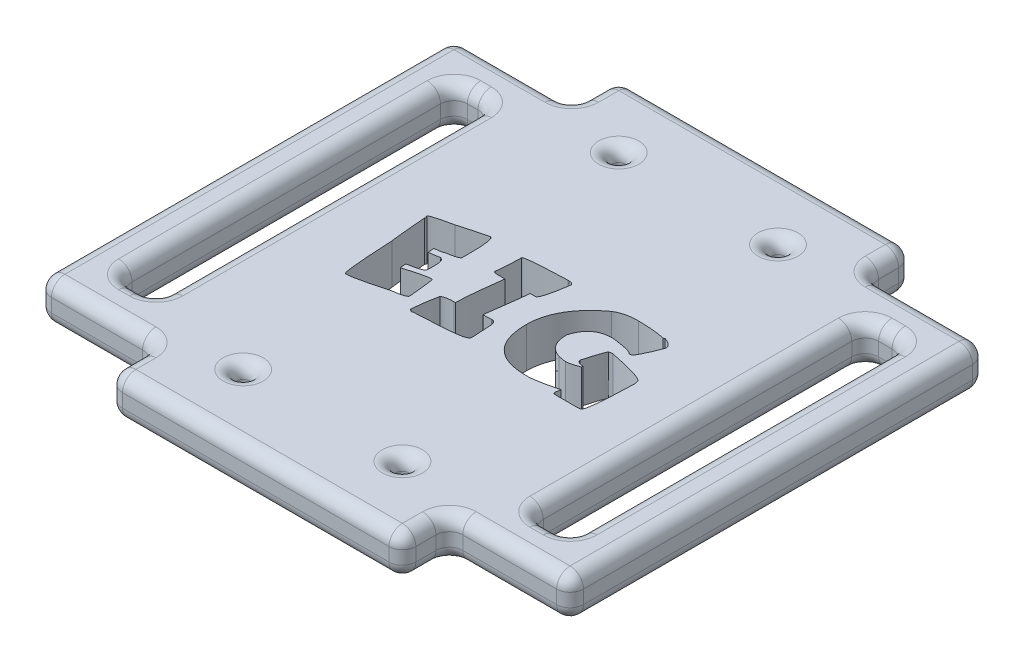
from build123d import *

# Parameters (mm, degrees)
SKETCH1_W           = 21.87178063
SKETCH1_H           = 38
BOSS_EXTRUDE2_DEPTH = 3
SKETCH8_W           = 8.788754456
SKETCH8_H           = 31
SKETCH8_W_2         = 2.788754456
SKETCH8_H_2         = 25
SKETCH8_W_3         = 9
SKETCH8_W_4         = 3
BOSS_EXTRUDE5_DEPTH = 3
SKETCH11_R          = 0.5
CUT_EXTRUDE5_DEPTH  = 3
FILLET1_R           = 1
CUT_EXTRUDE6_DEPTH  = 3


with BuildPart() as part:
    # Sketch1 → Boss-Extrude2 (new body)
    with BuildSketch(Plane(origin=(0, 0, 0), x_dir=(1, 0, 0), z_dir=(0, 1, 0))):
        with Locations((10.935890315, 19)):
            Rectangle(SKETCH1_W, SKETCH1_H)
    extrude(amount=BOSS_EXTRUDE2_DEPTH)

    # Sketch8 → Boss-Extrude5 (add)
    with BuildSketch(Plane(origin=(0, 0, 0), x_dir=(1, 0, 0), z_dir=(0, 1, 0))):
        with Locations((-4.394377228, 19)):
            Rectangle(SKETCH8_W, SKETCH8_H)
        with Locations((-4.394377228, 19)):
            Rectangle(SKETCH8_W_2, SKETCH8_H_2, mode=Mode.SUBTRACT)
        with Locations((26.37178063, 19)):
            Rectangle(SKETCH8_W_3, SKETCH8_H)
        with Locations((26.37178063, 19)):
            Rectangle(SKETCH8_W_4, SKETCH8_H_2, mode=Mode.SUBTRACT)
    extrude(amount=BOSS_EXTRUDE5_DEPTH)

    # Sketch11 → Cut-Extrude5 (cut)
    with BuildSketch(Plane(origin=(0, 3, 0), x_dir=(1, 0, 0), z_dir=(0, 1, 0))):
        with Locations((5, 33)):
            Circle(SKETCH11_R)
        with Locations((16.87178063, 33)):
            Circle(SKETCH11_R)
        with Locations((5, 5)):
            Circle(SKETCH11_R)
        with Locations((16.87178063, 5)):
            Circle(SKETCH11_R)
    extrude(amount=-CUT_EXTRUDE5_DEPTH, mode=Mode.SUBTRACT)

    # Fillet1
    fillet1_edges = [part.edges().sort_by_distance(p)[0] for p in [
        (21.87178063, 3, -1.75),
        (10.935890315, 3, 0),
        (0, 0, -36.25),
        (0, 3, -36.25),
        (-4.394377228, 3, -34.5),
        (-8.788754456, 3, -19),
        (-4.394377228, 3, -3.5),
        (-5.788754456, 0, -19),
        (-4.394377228, 0, -6.5),
        (-3, 0, -19),
        (-4.394377228, 0, -31.5),
        (0, 1.5, -3.5),
        (-4.394377228, 0, -34.5),
        (0, 1.5, -34.5),
        (-8.788754456, 0, -19),
        (-8.788754456, 1.5, -34.5),
        (-4.394377228, 0, -3.5),
        (-8.788754456, 1.5, -3.5),
        (-5.788754456, 3, -19),
        (-5.788754456, 1.5, -6.5),
        (-4.394377228, 3, -6.5),
        (-3, 1.5, -6.5),
        (-3, 3, -19),
        (-3, 1.5, -31.5),
        (-4.394377228, 3, -31.5),
        (-5.788754456, 1.5, -31.5),
        (21.87178063, 0, -36.25),
        (21.87178063, 3, -36.25),
        (26.37178063, 3, -3.5),
        (30.87178063, 3, -19),
        (26.37178063, 3, -34.5),
        (26.37178063, 0, -31.5),
        (24.87178063, 0, -19),
        (26.37178063, 0, -6.5),
        (27.87178063, 0, -19),
        (21.87178063, 1.5, -34.5),
        (26.37178063, 0, -3.5),
        (0, 3, -1.75),
        (21.87178063, 1.5, -3.5),
        (30.87178063, 0, -19),
        (30.87178063, 1.5, -3.5),
        (26.37178063, 0, -34.5),
        (30.87178063, 1.5, -34.5),
        (24.87178063, 3, -19),
        (24.87178063, 1.5, -6.5),
        (26.37178063, 3, -6.5),
        (27.87178063, 1.5, -6.5),
        (27.87178063, 3, -19),
        (27.87178063, 1.5, -31.5),
        (26.37178063, 3, -31.5),
        (24.87178063, 1.5, -31.5),
        (10.935890315, 0, 0),
        (21.87178063, 0, -1.75),
        (10.935890315, 0, -38),
        (0, 0, -1.75),
        (4.5, 0, -33),
        (4.5, 3, -33),
        (16.37178063, 0, -33),
        (16.37178063, 3, -33),
        (10.935890315, 3, -38),
        (4.5, 0, -5),
        (4.5, 3, -5),
        (0, 1.5, 0),
        (21.87178063, 1.5, 0),
        (16.37178063, 0, -5),
        (16.37178063, 3, -5),
        (21.87178063, 1.5, -38),
        (0, 1.5, -38),
    ]]
    fillet(fillet1_edges, radius=FILLET1_R)

    # Sketch12 → Cut-Extrude6 (cut)
    with BuildSketch(Plane(origin=(0, 3, 0), x_dir=(1, 0, 0), z_dir=(0, 1, 0))):
        with BuildLine():
            add(Edge.make_bspline(
                [(5.642624344, 22.792570725), (5.655466331, 22.791505959), (5.682191968, 22.789290059), (5.716989352, 22.762856545), (5.748967953, 22.725313861), (5.776606808, 22.672523144), (5.805171956, 22.606704005), (5.827818358, 22.525442439), (5.850904067, 22.430133811), (5.87229523, 22.320731153), (5.886895589, 22.195592443), (5.904131068, 22.057114578), (5.916705535, 21.903669902), (5.926050431, 21.735638976), (5.933978373, 21.553043254), (5.94097373, 21.355306996), (5.943569012, 21.143433631), (5.944468238, 20.997149901), (5.944931152, 20.921844182)],
                knots=[0, 0, 0, 0, 3.7943e-05, 7.8964e-05, 0.00012621, 0.000185883, 0.000256523, 0.000341367, 0.000438342, 0.000550864, 0.000675452, 0.00081617, 0.000969501, 0.001137191, 0.00132103, 0.0015178, 0.00173074, 0.001956663, 0.001956663, 0.001956663, 0.001956663], degree=3))
            Line((5.944931152, 20.921844182), (5.944931152, 20.395245225))
            add(Edge.make_bspline(
                [(5.944931152, 20.395245225), (5.940784352, 20.378845445), (5.931188198, 20.340894541), (5.877890139, 20.293142892), (5.797558315, 20.251716678), (5.687124518, 20.208152554), (5.546561599, 20.165056485), (5.374001105, 20.125679999), (5.171445995, 20.084758894), (5.025112876, 20.061481629), (4.946993622, 20.04905517)],
                knots=[0, 0, 0, 0, 4.9857e-05, 0.000115376, 0.000204885, 0.000322291, 0.000470345, 0.000645773, 0.000852959, 0.001090232, 0.001090232, 0.001090232, 0.001090232], degree=3))
            add(Edge.make_bspline(
                [(4.946993622, 20.04905517), (4.944019153, 20.044394332), (4.934791221, 20.029934642), (4.899001146, 20.019475717), (4.849489493, 20.002552453), (4.777124032, 19.986788344), (4.685466398, 19.971606278), (4.572871718, 19.953012604), (4.439935873, 19.936097044), (4.344547232, 19.923911231), (4.293620842, 19.917405431)],
                knots=[0, 0, 0, 0, 1.6253e-05, 5.0423e-05, 0.000104913, 0.000176666, 0.000270724, 0.000384286, 0.000518755, 0.000672773, 0.000672773, 0.000672773, 0.000672773], degree=3))
            Line((4.293620842, 19.917405431), (4.337504089, 19.457443996))
            add(Edge.make_bspline(
                [(4.337504089, 19.457443996), (4.423181774, 19.467158845), (4.586141628, 19.485636591), (4.815081481, 19.520602249), (5.017230558, 19.553072558), (5.141056657, 19.580945614), (5.198915963, 19.593969651)],
                knots=[0, 0, 0, 0, 0.000258648, 0.000491952, 0.000694757, 0.000872637, 0.000872637, 0.000872637, 0.000872637], degree=3))
            Line((5.198915963, 19.593969651), (5.198915963, 19.517580296))
            add(Edge.make_bspline(
                [(5.198915963, 19.517580296), (5.223141938, 19.518318728), (5.272511765, 19.519823568), (5.336030083, 19.461498346), (5.378446847, 19.370082328), (5.410436281, 19.241254867), (5.432033867, 19.074055144), (5.439734569, 18.867525958), (5.437841128, 18.621339932), (5.428329765, 18.444311496), (5.423208111, 18.348985697)],
                knots=[0, 0, 0, 0, 7.019e-05, 0.000143039, 0.000240463, 0.000371751, 0.000539086, 0.00074573, 0.000991157, 0.001277506, 0.001277506, 0.001277506, 0.001277506], degree=3))
            Line((5.423208111, 18.348985697), (5.423208111, 18.261219204))
            add(Edge.make_bspline(
                [(5.423208111, 18.261219204), (5.41838907, 18.246346326), (5.40605151, 18.208269241), (5.340745967, 18.16580422), (5.248440602, 18.122586417), (5.119552149, 18.072869954), (4.953887315, 18.026529482), (4.751453195, 17.976468556), (4.513320332, 17.922455374), (4.341420257, 17.890052979), (4.249737596, 17.872771208)],
                knots=[0, 0, 0, 0, 4.5884e-05, 0.000117472, 0.000220688, 0.000356515, 0.000529318, 0.000737059, 0.000981925, 0.001261789, 0.001261789, 0.001261789, 0.001261789], degree=3))
            Line((4.249737596, 17.872771208), (4.293620842, 17.422561605))
            add(Edge.make_bspline(
                [(4.293620842, 17.422561605), (4.416464971, 17.460410067), (4.649760981, 17.53228892), (4.982891098, 17.627116369), (5.278987907, 17.710515108), (5.539981773, 17.773234518), (5.764741807, 17.821719254), (5.953364997, 17.852815813), (6.106607755, 17.87092922), (6.196828061, 17.867677015), (6.235860823, 17.866269986)],
                knots=[0, 0, 0, 0, 0.000385612, 0.000732324, 0.00103909, 0.001308332, 0.001537523, 0.001728571, 0.001882048, 0.001999081, 0.001999081, 0.001999081, 0.001999081], degree=3))
            add(Edge.make_bspline(
                [(6.235860823, 17.866269986), (6.23817291, 17.86364691), (6.245514358, 17.855317992), (6.251924762, 17.831624688), (6.262059263, 17.795280086), (6.27089174, 17.74220314), (6.282082797, 17.675079158), (6.29579008, 17.592875474), (6.307638596, 17.496206028), (6.323279078, 17.384796853), (6.337129427, 17.257856776), (6.353276935, 17.115905034), (6.371764361, 16.95945917), (6.388982506, 16.788129649), (6.409097408, 16.601878641), (6.427934346, 16.400219201), (6.449260598, 16.184073385), (6.463946528, 16.035092694), (6.47153011, 15.958161419)],
                knots=[0, 0, 0, 0, 1.0407e-05, 3.3045e-05, 7.1678e-05, 0.000124594, 0.000193799, 0.000276097, 0.000374479, 0.000485963, 0.000613578, 0.000757526, 0.000914576, 0.001086167, 0.001274092, 0.001476571, 0.001693767, 0.001925679, 0.001925679, 0.001925679, 0.001925679], degree=3))
            add(Edge.make_bspline(
                [(6.47153011, 15.958161419), (6.467718394, 15.939440854), (6.459214149, 15.897673765), (6.402825272, 15.847006218), (6.324289683, 15.798634337), (6.21170402, 15.757167191), (6.070896754, 15.712334224), (5.896705534, 15.676202545), (5.692709108, 15.637618044), (5.545772626, 15.617739808), (5.467091358, 15.607095447)],
                knots=[0, 0, 0, 0, 5.6044e-05, 0.000125038, 0.000217036, 0.000334441, 0.000482496, 0.000660725, 0.000867298, 0.001105426, 0.001105426, 0.001105426, 0.001105426], degree=3))
            add(Edge.make_bspline(
                [(5.467091358, 15.607095447), (5.375483549, 15.582899664), (5.19759854, 15.535916038), (4.938830947, 15.464322162), (4.693285042, 15.402382979), (4.462838103, 15.341449209), (4.246562918, 15.286622714), (4.044892336, 15.235053043), (3.856799664, 15.192762378), (3.683844066, 15.150907876), (3.524999497, 15.115580997), (3.380424033, 15.084278585), (3.250141568, 15.058995235), (3.135158158, 15.035110627), (3.034210452, 15.018859659), (2.947922066, 15.008246267), (2.876042151, 14.998114493), (2.832497659, 14.997763387), (2.812967601, 14.997605913)],
                knots=[0, 0, 0, 0, 0.000284247, 0.000551954, 0.000805429, 0.001043928, 0.001267046, 0.001474786, 0.001668361, 0.00184537, 0.002008615, 0.002156526, 0.002289126, 0.002406744, 0.002508816, 0.002595705, 0.002667679, 0.002726212, 0.002726212, 0.002726212, 0.002726212], degree=3))
            Line((2.812967601, 14.997605913), (2.637434615, 14.997605913))
            add(Edge.make_bspline(
                [(2.637434615, 14.997605913), (2.628100123, 15.001779104), (2.602367573, 15.013283407), (2.581675581, 15.067298876), (2.554776322, 15.14015116), (2.532885423, 15.246778452), (2.505778127, 15.38096206), (2.48306052, 15.546799258), (2.458504048, 15.741770726), (2.434477408, 15.966150285), (2.410085946, 16.22024621), (2.386028232, 16.504715042), (2.361137037, 16.819419714), (2.339777068, 17.164159234), (2.314017121, 17.538368422), (2.292313837, 17.942631109), (2.269215194, 18.37711151), (2.25481049, 18.676748579), (2.247361314, 18.831701408)],
                knots=[0, 0, 0, 0, 2.9837e-05, 8.2251e-05, 0.000161409, 0.000268247, 0.000405631, 0.000573195, 0.00076975, 0.000995363, 0.00125008, 0.001535551, 0.001851802, 0.002197117, 0.002571731, 0.002977072, 0.003411624, 0.003877018, 0.003877018, 0.003877018, 0.003877018], degree=3))
            add(Edge.make_bspline(
                [(2.247361314, 18.831701408), (2.24499605, 18.835419283), (2.23664709, 18.848542723), (2.234564837, 18.883750819), (2.222333616, 18.936282291), (2.214199892, 19.011638916), (2.202384899, 19.106824218), (2.189780613, 19.223394714), (2.174850218, 19.360957845), (2.159029863, 19.519204029), (2.140505756, 19.698415818), (2.123339574, 19.898448591), (2.103629728, 20.119470353), (2.082570179, 20.361647594), (2.059880328, 20.624410813), (2.035431982, 20.908291294), (2.009129737, 21.21269658), (1.992587191, 21.422968248), (1.984061835, 21.531333716)],
                knots=[0, 0, 0, 0, 1.3104e-05, 4.6253e-05, 0.000102368, 0.000176154, 0.000272719, 0.000390461, 0.000527768, 0.000687876, 0.000867551, 0.001068261, 0.001290162, 0.001533252, 0.001797533, 0.002081385, 0.002388047, 0.002714147, 0.002714147, 0.002714147, 0.002714147], degree=3))
            add(Edge.make_bspline(
                [(1.984061835, 21.531333716), (1.996543053, 21.5551949), (2.018319545, 21.596826486), (2.025065554, 21.643192267), (2.027945082, 21.662983456)],
                knots=[0, 0, 0, 0, 8.0037e-05, 0.000139644, 0.000139644, 0.000139644, 0.000139644], degree=3))
            add(Edge.make_bspline(
                [(2.027945082, 21.662983456), (2.01453787, 21.663266281), (1.99067177, 21.663769736), (1.962004914, 21.682766158), (1.940867521, 21.709090419), (1.940421363, 21.731859227), (1.940178589, 21.744248727)],
                knots=[0, 0, 0, 0, 3.9311e-05, 6.9977e-05, 0.00010021, 0.000136297, 0.000136297, 0.000136297, 0.000136297], degree=3))
            add(Edge.make_bspline(
                [(1.940178589, 21.744248727), (1.941932417, 21.750437063), (1.94633718, 21.765979148), (1.968135496, 21.785969846), (2.000373713, 21.806932465), (2.043960705, 21.831573989), (2.101655323, 21.85500952), (2.171132399, 21.88075397), (2.252934804, 21.908517223), (2.347287349, 21.93758776), (2.454595246, 21.968405524), (2.574432734, 22.000557535), (2.706574795, 22.034907666), (2.851258262, 22.070578775), (3.008954527, 22.107799903), (3.178888087, 22.147126492), (3.361872922, 22.185358118), (3.487491213, 22.212778252), (3.552481569, 22.226964438)],
                knots=[0, 0, 0, 0, 1.9024e-05, 4.7778e-05, 8.5196e-05, 0.000135396, 0.000197286, 0.000271856, 0.00035769, 0.000456393, 0.000568019, 0.000692607, 0.000828609, 0.000977615, 0.001139641, 0.0013147, 0.001500866, 0.001700428, 0.001700428, 0.001700428, 0.001700428], degree=3))
            add(Edge.make_bspline(
                [(3.552481569, 22.226964438), (3.590890717, 22.239605133), (3.681403619, 22.269393506), (3.838853884, 22.315515399), (4.037622598, 22.372610892), (4.27799413, 22.43941013), (4.560655428, 22.513239901), (4.8845165, 22.598201733), (5.249769353, 22.692086849), (5.507175118, 22.75792572), (5.642624344, 22.792570725)],
                knots=[0, 0, 0, 0, 0.0001213, 0.00028585, 0.000492136, 0.000741741, 0.00103426, 0.001368555, 0.001746204, 0.002165633, 0.002165633, 0.002165633, 0.002165633], degree=3))
        make_face()
        with BuildLine():
            Line((11.342570464, 22.86896008), (11.418959819, 22.86896008))
            add(Edge.make_bspline(
                [(11.418959819, 22.86896008), (11.458685805, 22.867265495), (11.533426755, 22.864077283), (11.636501157, 22.836192064), (11.720170588, 22.783693194), (11.75778699, 22.734291471), (11.776527012, 22.709680148)],
                knots=[0, 0, 0, 0, 0.000119047, 0.000223977, 0.000316847, 0.000409047, 0.000409047, 0.000409047, 0.000409047], degree=3))
            add(Edge.make_bspline(
                [(11.776527012, 22.709680148), (11.763552204, 22.624618478), (11.738422408, 22.459869803), (11.701492583, 22.220786526), (11.664106949, 21.998102564), (11.626857484, 21.791645433), (11.589571145, 21.601438796), (11.552506085, 21.427973699), (11.51533915, 21.271283374), (11.477341725, 21.131799243), (11.443012873, 21.007427711), (11.404911875, 20.900637689), (11.36984499, 20.809013955), (11.335074989, 20.733956724), (11.29871115, 20.675569445), (11.264325785, 20.633132318), (11.228483767, 20.603854145), (11.202098867, 20.600140579), (11.189791755, 20.598408403)],
                knots=[0, 0, 0, 0, 0.000258137, 0.000499964, 0.000725747, 0.000935518, 0.001129318, 0.001307198, 0.001467643, 0.001612332, 0.001740926, 0.001854524, 0.001952312, 0.002035187, 0.002102377, 0.002157733, 0.002199677, 0.002236346, 0.002236346, 0.002236346, 0.002236346], degree=3))
            Line((11.189791755, 20.598408403), (10.794842537, 20.598408403))
            Line((10.794842537, 20.598408403), (10.794842537, 20.559401073))
            add(Edge.make_bspline(
                [(10.794842537, 20.559401073), (10.794392226, 20.548017683), (10.793189497, 20.517613963), (10.787374977, 20.46191616), (10.782091703, 20.38476501), (10.76882665, 20.287009765), (10.757708536, 20.167484279), (10.738063706, 20.027502709), (10.719453085, 19.865882044), (10.696575683, 19.683318777), (10.670479725, 19.479083418), (10.640830732, 19.254369405), (10.610914205, 19.00760031), (10.573973501, 18.740803991), (10.537760369, 18.451743491), (10.494419069, 18.142682566), (10.451084959, 17.811515929), (10.420547537, 17.583999657), (10.404769235, 17.466444852)],
                knots=[0, 0, 0, 0, 3.417e-05, 9.1264e-05, 0.00016793, 0.00026611, 0.000387083, 0.000527998, 0.000690081, 0.000875145, 0.001079965, 0.001307769, 0.001555126, 0.001825674, 0.002115772, 0.002429068, 0.002761911, 0.003117738, 0.003117738, 0.003117738, 0.003117738], degree=3))
            Line((10.404769235, 17.466444852), (10.443776565, 17.466444852))
            add(Edge.make_bspline(
                [(10.443776565, 17.466444852), (10.480630888, 17.466600532), (10.562545839, 17.466946556), (10.696820812, 17.476918856), (10.855650231, 17.487518543), (10.969313396, 17.498119252), (11.030511823, 17.503826877)],
                knots=[0, 0, 0, 0, 0.000110533, 0.000245678, 0.000403742, 0.00058812, 0.00058812, 0.00058812, 0.00058812], degree=3))
            add(Edge.make_bspline(
                [(11.030511823, 17.503826877), (11.058370731, 17.502497677), (11.111501902, 17.499962693), (11.184987181, 17.474436159), (11.247968854, 17.434664803), (11.297604223, 17.376408423), (11.336902155, 17.303402878), (11.3636909, 17.213924923), (11.379576902, 17.109451497), (11.380884629, 17.034718681), (11.381577795, 16.995106279)],
                knots=[0, 0, 0, 0, 8.3288e-05, 0.000158843, 0.000230522, 0.000304219, 0.000385679, 0.000477692, 0.000582973, 0.000701721, 0.000701721, 0.000701721, 0.000701721], degree=3))
            add(Edge.make_bspline(
                [(11.381577795, 16.995106279), (11.384420221, 16.967487957), (11.39104465, 16.903121974), (11.398626263, 16.793074211), (11.406368573, 16.656494363), (11.416244664, 16.493428006), (11.427896107, 16.303855844), (11.439145006, 16.087677075), (11.450119224, 15.844919386), (11.458451807, 15.674272055), (11.462843066, 15.584341171)],
                knots=[0, 0, 0, 0, 8.3288e-05, 0.000194107, 0.000330874, 0.000493697, 0.000684198, 0.000900663, 0.0011431, 0.001413214, 0.001413214, 0.001413214, 0.001413214], degree=3))
            add(Edge.make_bspline(
                [(11.462843066, 15.584341171), (11.461748493, 15.569932858), (11.459518205, 15.540574648), (11.434654921, 15.500152727), (11.400660514, 15.460323399), (11.349878421, 15.425681691), (11.287846776, 15.390732307), (11.210392472, 15.361686052), (11.121593974, 15.329835064), (11.01752801, 15.302919839), (10.900493431, 15.277104924), (10.769121973, 15.254740693), (10.624425802, 15.233659738), (10.465616125, 15.21441581), (10.293293276, 15.196741748), (10.107517112, 15.180001647), (9.907491209, 15.167620398), (9.769281067, 15.16054642), (9.697761376, 15.156885845)],
                knots=[0, 0, 0, 0, 4.2755e-05, 8.7117e-05, 0.000138949, 0.000199414, 0.000269979, 0.000352374, 0.00044695, 0.000553006, 0.00067447, 0.00080647, 0.000952658, 0.001113127, 0.001286335, 0.001472331, 0.001672666, 0.001887508, 0.001887508, 0.001887508, 0.001887508], degree=3))
            add(Edge.make_bspline(
                [(9.697761376, 15.156885845), (9.572619374, 15.147581372), (9.333190765, 15.129779539), (8.9907668, 15.10580978), (8.681522161, 15.083461469), (8.405592848, 15.068985207), (8.16308762, 15.051828019), (7.953792009, 15.045787423), (7.777795171, 15.037377119), (7.671555005, 15.036849882), (7.623871655, 15.036613243)],
                knots=[0, 0, 0, 0, 0.000376461, 0.000720266, 0.001029796, 0.001306575, 0.001549187, 0.001759009, 0.001934662, 0.002077699, 0.002077699, 0.002077699, 0.002077699], degree=3))
            Line((7.623871655, 15.036613243), (7.5474823, 14.997605913))
            add(Edge.make_bspline(
                [(7.5474823, 14.997605913), (7.519870786, 15.009756392), (7.470719061, 15.031385666), (7.410719239, 15.071760073), (7.365659833, 15.110235744), (7.354192774, 15.14272564), (7.349195039, 15.156885845)],
                knots=[0, 0, 0, 0, 9.0142e-05, 0.000160464, 0.000217927, 0.000262319, 0.000262319, 0.000262319, 0.000262319], degree=3))
            add(Edge.make_bspline(
                [(7.349195039, 15.156885845), (7.363083576, 15.319011096), (7.390590288, 15.640105585), (7.453850244, 16.114753226), (7.528819566, 16.57851121), (7.592382509, 16.882093388), (7.623871655, 17.032488304)],
                knots=[0, 0, 0, 0, 0.000488093, 0.000966684, 0.001436152, 0.001897063, 0.001897063, 0.001897063, 0.001897063], degree=3))
            add(Edge.make_bspline(
                [(7.623871655, 17.032488304), (7.643887198, 17.049074892), (7.685999922, 17.083973092), (7.76433863, 17.120654542), (7.853096895, 17.155625175), (7.95478868, 17.184516452), (8.069697249, 17.20509968), (8.196805665, 17.218921781), (8.336673363, 17.229255142), (8.434335723, 17.230254321), (8.48528353, 17.230775565)],
                knots=[0, 0, 0, 0, 7.7692e-05, 0.000163465, 0.000257634, 0.000364126, 0.000479843, 0.000607458, 0.000747574, 0.000900387, 0.000900387, 0.000900387, 0.000900387], degree=3))
            Line((8.48528353, 17.230775565), (8.600680215, 17.230775565))
            add(Edge.make_bspline(
                [(8.600680215, 17.230775565), (8.601764244, 17.319099867), (8.60411307, 17.510476861), (8.620254422, 17.819874425), (8.644161962, 18.174327724), (8.681467884, 18.572887203), (8.72426893, 19.016298353), (8.78132525, 19.503595264), (8.843214575, 20.036477844), (8.892159119, 20.40614669), (8.917614772, 20.598408403)],
                knots=[0, 0, 0, 0, 0.00026497, 0.000574124, 0.000929278, 0.001330699, 0.001774955, 0.002265668, 0.002802523, 0.00338433, 0.00338433, 0.00338433, 0.00338433], degree=3))
            Line((8.917614772, 20.598408403), (8.286996268, 20.598408403))
            add(Edge.make_bspline(
                [(8.286996268, 20.598408403), (8.256370743, 20.598911005), (8.201595144, 20.59980994), (8.130709309, 20.622798916), (8.076210719, 20.658924279), (8.062747867, 20.695852449), (8.056202898, 20.713805088)],
                knots=[0, 0, 0, 0, 9.1249e-05, 0.000163204, 0.000222366, 0.000278339, 0.000278339, 0.000278339, 0.000278339], degree=3))
            add(Edge.make_bspline(
                [(8.056202898, 20.713805088), (8.065678504, 20.81129951), (8.084041576, 21.000236989), (8.106451825, 21.276087206), (8.126064671, 21.535591991), (8.142337695, 21.778855679), (8.155389976, 22.00586187), (8.165708512, 22.216046536), (8.170467827, 22.41060061), (8.171232382, 22.53468714), (8.171599583, 22.594283463)],
                knots=[0, 0, 0, 0, 0.000293857, 0.000569474, 0.000830254, 0.001074591, 0.001300882, 0.001512396, 0.001705869, 0.00188466, 0.00188466, 0.00188466, 0.00188466], degree=3))
            add(Edge.make_bspline(
                [(8.171599583, 22.594283463), (8.175463187, 22.601272156), (8.186040162, 22.620404356), (8.229061377, 22.637022568), (8.2900118, 22.655908459), (8.378531965, 22.67230932), (8.489113277, 22.6924915), (8.62548777, 22.709257606), (8.786255635, 22.727842331), (8.972370553, 22.742367495), (9.182904187, 22.761764954), (9.418176425, 22.776892767), (9.678215012, 22.793232733), (9.963136167, 22.810076514), (10.273152352, 22.823309268), (10.607854279, 22.840894575), (10.967113674, 22.854654768), (11.214713433, 22.864088588), (11.342570464, 22.86896008)],
                knots=[0, 0, 0, 0, 2.344e-05, 6.4171e-05, 0.00013049, 0.000218467, 0.000332296, 0.000468376, 0.000630272, 0.000817887, 0.001028313, 0.001264542, 0.001525098, 0.00180999, 0.002120768, 0.002455975, 0.002815466, 0.003199316, 0.003199316, 0.003199316, 0.003199316], degree=3))
        make_face()
        with BuildLine():
            add(Edge.make_bspline(
                [(16.615061259, 22.86896008), (16.798241065, 22.866328508), (17.155206237, 22.861200324), (17.677124693, 22.825271593), (18.171835811, 22.76566095), (18.489895859, 22.702911622), (18.645067733, 22.672298124)],
                knots=[0, 0, 0, 0, 0.000549507, 0.001070833, 0.00156877, 0.00204312, 0.00204312, 0.00204312, 0.00204312], degree=3))
            Line((18.645067733, 22.672298124), (18.742586058, 22.721057286))
            add(Edge.make_bspline(
                [(18.742586058, 22.721057286), (18.793332749, 22.702993012), (18.889309792, 22.668828113), (19.020308714, 22.606526051), (19.131848698, 22.540854434), (19.222821276, 22.468780795), (19.294527529, 22.391913751), (19.346006023, 22.309318212), (19.379478016, 22.221311659), (19.382880293, 22.16007118), (19.384581701, 22.129446112)],
                knots=[0, 0, 0, 0, 0.000161503, 0.000305451, 0.000434507, 0.000548984, 0.00065252, 0.000748137, 0.000839646, 0.000931184, 0.000931184, 0.000931184, 0.000931184], degree=3))
            add(Edge.make_bspline(
                [(19.384581701, 22.129446112), (19.357597674, 22.059517639), (19.305224669, 21.923794221), (19.227340088, 21.727067776), (19.152382457, 21.544250493), (19.08318035, 21.373914452), (19.01432127, 21.219141142), (18.951702894, 21.076329215), (18.889210566, 20.94875817), (18.832777551, 20.832867338), (18.779725293, 20.730619366), (18.728907965, 20.642508372), (18.682790226, 20.567420271), (18.638260622, 20.507542584), (18.599833426, 20.458412937), (18.562376524, 20.424594533), (18.528906329, 20.400344349), (18.505531317, 20.396772162), (18.495539634, 20.395245225)],
                knots=[0, 0, 0, 0, 0.000224863, 0.000436433, 0.000634727, 0.000817637, 0.000987946, 0.001142905, 0.001285386, 0.001414042, 0.001529633, 0.001630834, 0.001719215, 0.00179366, 0.001854842, 0.001905462, 0.001945604, 0.001975573, 0.001975573, 0.001975573, 0.001975573], degree=3))
            Line((18.495539634, 20.395245225), (18.34763684, 20.395245225))
            add(Edge.make_bspline(
                [(18.34763684, 20.395245225), (18.341401836, 20.412538064), (18.32518329, 20.457520343), (18.242059635, 20.50302202), (18.126193834, 20.549453058), (17.962431717, 20.600202246), (17.75318595, 20.646497331), (17.497042549, 20.694673434), (17.195459848, 20.745498054), (16.978152525, 20.774634966), (16.862107683, 20.790194443)],
                knots=[0, 0, 0, 0, 5.3807e-05, 0.000139964, 0.000266738, 0.000435347, 0.000650606, 0.000910396, 0.001216873, 0.001568089, 0.001568089, 0.001568089, 0.001568089], degree=3))
            Line((16.862107683, 20.790194443), (16.714204889, 20.790194443))
            add(Edge.make_bspline(
                [(16.714204889, 20.790194443), (16.655668848, 20.788663283), (16.540543589, 20.785651886), (16.37187765, 20.77039035), (16.211177582, 20.740364385), (16.058342496, 20.700089559), (15.912257605, 20.648050554), (15.775046162, 20.582962448), (15.644551533, 20.507610282), (15.522832142, 20.419676797), (15.409081628, 20.320162973), (15.302295434, 20.210052876), (15.202534156, 20.088567472), (15.114591476, 19.952423923), (15.030150951, 19.807425596), (14.956612166, 19.649751685), (14.889027679, 19.481054724), (14.851414756, 19.363435367), (14.832101209, 19.303039981)],
                knots=[0, 0, 0, 0, 0.000175653, 0.000345465, 0.000507409, 0.000665499, 0.000819217, 0.0009719, 0.00112048, 0.001270687, 0.001421596, 0.001573316, 0.001730442, 0.001892272, 0.002058991, 0.002233475, 0.002413656, 0.002603824, 0.002603824, 0.002603824, 0.002603824], degree=3))
            Line((14.832101209, 19.303039981), (14.832101209, 19.254280818))
            add(Edge.make_bspline(
                [(14.832101209, 19.254280818), (14.835554167, 19.153305782), (14.842191272, 18.959216569), (14.892080664, 18.681201321), (14.978349791, 18.431667971), (15.098518482, 18.208858706), (15.254092743, 18.015061538), (15.446243181, 17.851744107), (15.670333521, 17.714899546), (15.837999371, 17.651736928), (15.924306454, 17.619223562)],
                knots=[0, 0, 0, 0, 0.000302835, 0.000582094, 0.000843728, 0.00109174, 0.001337957, 0.001584586, 0.001844929, 0.002121107, 0.002121107, 0.002121107, 0.002121107], degree=3))
            add(Edge.make_bspline(
                [(15.924306454, 17.619223562), (15.994698123, 17.604924803), (16.121223519, 17.579223522), (16.290066603, 17.547770424), (16.416905959, 17.528153566), (16.487712235, 17.523542168), (16.515917628, 17.521705236)],
                knots=[0, 0, 0, 0, 0.000215474, 0.000387304, 0.000515332, 0.000600097, 0.000600097, 0.000600097, 0.000600097], degree=3))
            add(Edge.make_bspline(
                [(16.515917628, 17.521705236), (16.543580841, 17.522306574), (16.60237011, 17.523584525), (16.695207303, 17.536014408), (16.797746212, 17.555576238), (16.909689858, 17.583969166), (17.032334374, 17.618096878), (17.16472627, 17.660050107), (17.30627708, 17.71116554), (17.403388054, 17.748023542), (17.453718857, 17.767126355)],
                knots=[0, 0, 0, 0, 8.2954e-05, 0.000176293, 0.000280528, 0.000396028, 0.000522614, 0.000662428, 0.000812538, 0.000974041, 0.000974041, 0.000974041, 0.000974041], degree=3))
            Line((17.453718857, 17.767126355), (17.453718857, 17.866269986))
            add(Edge.make_bspline(
                [(17.453718857, 17.866269986), (17.415135373, 17.871546295), (17.342295916, 17.881507122), (17.241677902, 17.905776357), (17.156150169, 17.934955285), (17.084896633, 17.967922464), (17.029348589, 18.009370398), (16.988973559, 18.056844704), (16.964530508, 18.111230222), (16.961267447, 18.149384033), (16.959626008, 18.168576795)],
                knots=[0, 0, 0, 0, 0.000116773, 0.00022045, 0.000309886, 0.000387663, 0.000454951, 0.000516133, 0.000572902, 0.000630366, 0.000630366, 0.000630366, 0.000630366], degree=3))
            add(Edge.make_bspline(
                [(16.959626008, 18.168576795), (16.977314045, 18.232560018), (17.011539929, 18.356365869), (17.064210628, 18.5348042), (17.112226041, 18.70151515), (17.160910089, 18.855121727), (17.200572571, 18.9983726), (17.245163366, 19.126609302), (17.281285655, 19.244389842), (17.317252668, 19.349260696), (17.34971412, 19.441914719), (17.378685992, 19.522441492), (17.406428408, 19.589915864), (17.430151404, 19.646344136), (17.453436454, 19.688963142), (17.469977934, 19.721771281), (17.487388076, 19.741073013), (17.499633114, 19.74642123), (17.504103325, 19.748373667)],
                knots=[0, 0, 0, 0, 0.000199145, 0.00038534, 0.000558143, 0.000719581, 0.000868719, 0.001003894, 0.001126741, 0.001238273, 0.001336453, 0.001421297, 0.001494939, 0.001555339, 0.00160477, 0.001640453, 0.001665737, 0.001680274, 0.001680274, 0.001680274, 0.001680274], degree=3))
            add(Edge.make_bspline(
                [(17.504103325, 19.748373667), (17.519071803, 19.755906469), (17.552156765, 19.77255629), (17.610523332, 19.787898044), (17.679988214, 19.795057365), (17.729462152, 19.79640777), (17.756025666, 19.797132829)],
                knots=[0, 0, 0, 0, 5.0174e-05, 0.000110901, 0.000179646, 0.000259352, 0.000259352, 0.000259352, 0.000259352], degree=3))
            add(Edge.make_bspline(
                [(17.756025666, 19.797132829), (17.866015286, 19.774431151), (18.078506472, 19.730573315), (18.387106435, 19.665987345), (18.673688205, 19.601297201), (18.939317382, 19.53684002), (19.184354645, 19.478338925), (19.40738388, 19.417801587), (19.60909907, 19.358537506), (19.790973093, 19.305006927), (19.950685151, 19.249463433), (20.088523208, 19.195481833), (20.206569603, 19.146905526), (20.301567467, 19.09570489), (20.37730328, 19.048015921), (20.431644631, 19.001853363), (20.468101136, 18.956062757), (20.47405869, 18.923158998), (20.476786945, 18.908090763)],
                knots=[0, 0, 0, 0, 0.000336925, 0.000650912, 0.000945845, 0.001218248, 0.001470929, 0.001701574, 0.001911433, 0.00210167, 0.002270264, 0.002418461, 0.002545869, 0.002652757, 0.002742015, 0.002813418, 0.002867078, 0.002912412, 0.002912412, 0.002912412, 0.002912412], degree=3))
            Line((20.476786945, 18.908090763), (20.525546108, 18.662669644))
            add(Edge.make_bspline(
                [(20.525546108, 18.662669644), (20.521438308, 18.523427453), (20.513477626, 18.25358409), (20.498216808, 17.861923499), (20.484163022, 17.496182868), (20.468183114, 17.156461087), (20.4494616, 16.842857226), (20.433393179, 16.554958543), (20.410224228, 16.293556599), (20.392848186, 16.05699664), (20.369130982, 15.846950254), (20.347248386, 15.662548299), (20.323103623, 15.504711236), (20.297816435, 15.372885704), (20.270501911, 15.266137098), (20.243296866, 15.186338572), (20.219261575, 15.126392276), (20.192057739, 15.105326669), (20.180981358, 15.096749544)],
                knots=[0, 0, 0, 0, 0.000417906, 0.000809877, 0.001175864, 0.001515941, 0.001830134, 0.002118368, 0.002380894, 0.002617369, 0.00282988, 0.003014944, 0.003174473, 0.003308666, 0.003417864, 0.003503698, 0.003564032, 0.003605469, 0.003605469, 0.003605469, 0.003605469], degree=3))
            add(Edge.make_bspline(
                [(20.180981358, 15.096749544), (20.17551994, 15.080650225), (20.161987917, 15.040760157), (20.080316075, 15.016280012), (19.973610626, 15.000172747), (19.885652037, 14.998546352), (19.834791303, 14.997605913)],
                knots=[0, 0, 0, 0, 4.8705e-05, 0.000120679, 0.000231032, 0.000382325, 0.000382325, 0.000382325, 0.000382325], degree=3))
            Line((19.834791303, 14.997605913), (18.199734047, 14.997605913))
            add(Edge.make_bspline(
                [(18.199734047, 14.997605913), (18.184475316, 14.999246125), (18.155151434, 15.002398245), (18.120179025, 15.035275451), (18.103386079, 15.085592758), (18.101607632, 15.123707993), (18.100590416, 15.145508707)],
                knots=[0, 0, 0, 0, 4.4954e-05, 8.6391e-05, 0.000135285, 0.000200622, 0.000200622, 0.000200622, 0.000200622], degree=3))
            add(Edge.make_bspline(
                [(18.100590416, 15.145508707), (18.101568895, 15.159063623), (18.104473362, 15.199299364), (18.115768212, 15.278725644), (18.128897934, 15.397156179), (18.142970637, 15.48850226), (18.150974884, 15.540457925)],
                knots=[0, 0, 0, 0, 4.0762e-05, 0.000120997, 0.000240543, 0.000398223, 0.000398223, 0.000398223, 0.000398223], degree=3))
            add(Edge.make_bspline(
                [(18.150974884, 15.540457925), (18.032455827, 15.509070364), (17.804056169, 15.448582978), (17.471678565, 15.369271326), (17.164116698, 15.300491842), (16.879547168, 15.244921928), (16.619526708, 15.200641306), (16.382676639, 15.169107007), (16.1700307, 15.15034553), (16.035941298, 15.147052729), (15.973065616, 15.145508707)],
                knots=[0, 0, 0, 0, 0.000367801, 0.000708793, 0.001025056, 0.001313208, 0.001578536, 0.00181622, 0.002029884, 0.002218532, 0.002218532, 0.002218532, 0.002218532], degree=3))
            add(Edge.make_bspline(
                [(15.973065616, 15.145508707), (15.839147648, 15.147859144), (15.5788394, 15.152427896), (15.201693351, 15.19179835), (14.85017455, 15.255709332), (14.525143357, 15.347478932), (14.224062214, 15.460989307), (13.950534837, 15.60602762), (13.701508019, 15.774510181), (13.480946274, 15.972263039), (13.283193416, 16.192824785), (13.114710854, 16.441851603), (12.969672541, 16.71537898), (12.856162166, 17.016460123), (12.764392566, 17.341491315), (12.700481584, 17.693010117), (12.661111131, 18.070156166), (12.656542378, 18.330464414), (12.654191941, 18.464382382)],
                knots=[0, 0, 0, 0, 0.000401661, 0.000780744, 0.001136181, 0.001472179, 0.001792727, 0.002099531, 0.00239887, 0.002692439, 0.002986008, 0.003285347, 0.003592151, 0.003912699, 0.004248697, 0.004604134, 0.004983217, 0.005384878, 0.005384878, 0.005384878, 0.005384878], degree=3))
            add(Edge.make_bspline(
                [(12.654191941, 18.464382382), (12.656338473, 18.558699826), (12.660602483, 18.746058117), (12.68652258, 19.025336921), (12.732593839, 19.299912371), (12.795257198, 19.570740008), (12.879846661, 19.835961092), (12.977872358, 20.098534864), (13.097463062, 20.355416386), (13.234679077, 20.608076184), (13.388964112, 20.856909095), (13.562355403, 21.101037624), (13.752311123, 21.342240939), (13.962591089, 21.577549517), (14.190986097, 21.808544195), (14.436333403, 22.036110831), (14.700172938, 22.259238494), (14.885684307, 22.401619813), (14.980004002, 22.474010862)],
                knots=[0, 0, 0, 0, 0.000282971, 0.000562112, 0.000840533, 0.00111768, 0.00139527, 0.001675096, 0.001957979, 0.002244517, 0.002537225, 0.002835751, 0.003142383, 0.003457818, 0.003781919, 0.004116593, 0.004461423, 0.00481808, 0.00481808, 0.00481808, 0.00481808], degree=3))
            add(Edge.make_bspline(
                [(14.980004002, 22.474010862), (15.032473951, 22.506058526), (15.139410875, 22.571373603), (15.314427745, 22.648845895), (15.500159472, 22.718391629), (15.699032443, 22.772384263), (15.909951876, 22.817138544), (16.133793154, 22.847140543), (16.370428263, 22.865059263), (16.532137938, 22.867637819), (16.615061259, 22.86896008)],
                knots=[0, 0, 0, 0, 0.000184263, 0.000375538, 0.000572998, 0.000778841, 0.000993049, 0.001219457, 0.001455804, 0.00170456, 0.00170456, 0.00170456, 0.00170456], degree=3))
        make_face()
    extrude(amount=-CUT_EXTRUDE6_DEPTH, mode=Mode.SUBTRACT)


solid = part.part
